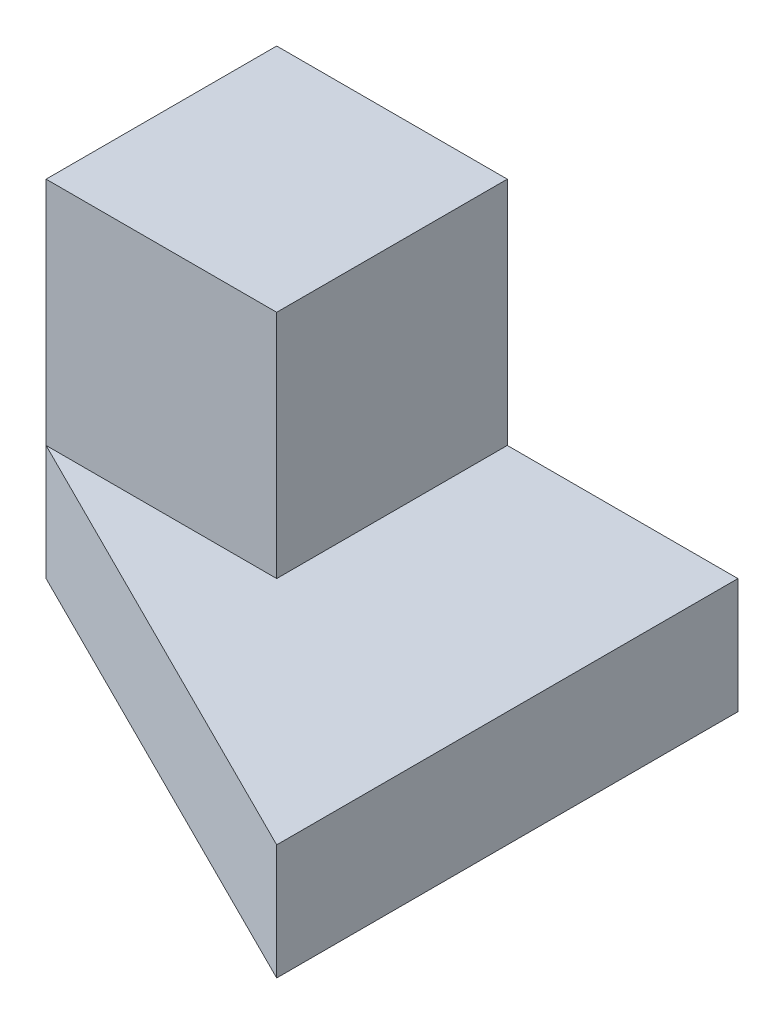
from build123d import *

# Parameters (mm, degrees)
BOSS_EXTRUDE2_DEPTH = 254
SKETCH3_3_W         = 508
SKETCH3_3_H         = 508
BOSS_EXTRUDE3_DEPTH = 762


with BuildPart() as part:
    # Sketch3 → Boss-Extrude2 (new body)
    with BuildSketch(Plane(origin=(0, 0, 0), x_dir=(1, 0, 0), z_dir=(0, 1, 0))):
        Polygon((1016, 0), (508, 0), (508, -508), (0, -508), (1016, -1016), align=None)
    extrude(amount=BOSS_EXTRUDE2_DEPTH)

    # Sketch3_3 → Boss-Extrude3 (add)
    with BuildSketch(Plane(origin=(0, 0, 0), x_dir=(1, 0, 0), z_dir=(0, 1, 0))):
        with Locations((254, -254)):
            Rectangle(SKETCH3_3_W, SKETCH3_3_H)
    extrude(amount=BOSS_EXTRUDE3_DEPTH)


solid = part.part
